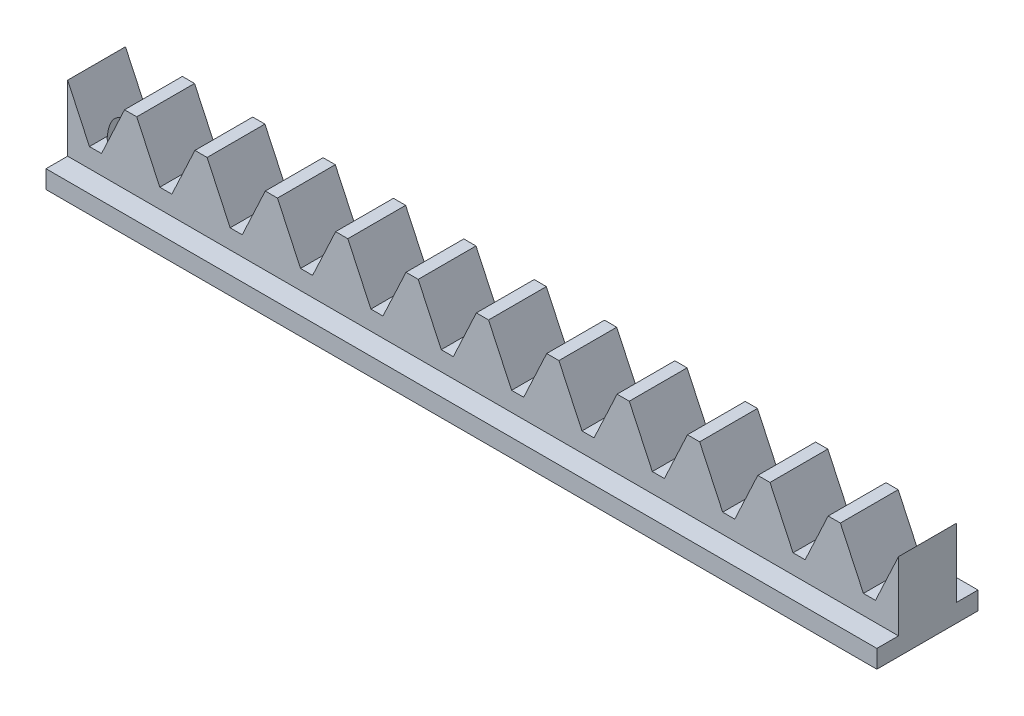
from build123d import *

# Parameters (mm, degrees)
BOSS_EXTRUDE4_DEPTH = 4
CUT_EXTRUDE7_DEPTH  = 5
LPATTERN2_COUNT     = 13
LPATTERN2_PITCH     = 9.7389
SKETCH10_W          = 14
SKETCH10_H          = 2.5
BOSS_EXTRUDE5_DEPTH = 115
SKETCH11_R          = 2.5
CUT_EXTRUDE8_DEPTH  = 13


with BuildPart() as part:
    # Sketch9 → Boss-Extrude4 (new body, symmetric)
    with BuildSketch(Plane.XY):
        Polygon((57.5, 6), (49.449989311, 6), (52.64, -0.841), (54.309989311, -0.841), align=None)
        Polygon((52.64, -0.841), (49.449989311, 6), (-57.5, 6), (-57.5, -6), (57.5, -6), (57.5, 6), (54.309989311, -0.841), align=None)
    extrude(amount=BOSS_EXTRUDE4_DEPTH, both=True)

    # Sketch9_4 → Cut-Extrude7 (cut, symmetric)
    with BuildSketch(Plane.XY):
        Polygon((57.5, 6), (49.449989311, 6), (52.64, -0.841), (54.309989311, -0.841), align=None)
    cut_extrude7 = extrude(amount=CUT_EXTRUDE7_DEPTH, both=True, mode=Mode.SUBTRACT)

    # LPattern2: Cut-Extrude7 ×13
    with Locations(*[(-i * LPATTERN2_PITCH, 0, 0) for i in range(1, LPATTERN2_COUNT)]):
        add(cut_extrude7, mode=Mode.SUBTRACT)

    # Sketch10 → Boss-Extrude5 (add)
    with BuildSketch(Plane.ZY.offset(57.5)):
        with Locations((0, -4.75)):
            Rectangle(SKETCH10_W, SKETCH10_H)
    extrude(amount=-BOSS_EXTRUDE5_DEPTH)

    # Sketch11 → Cut-Extrude8 (cut, through all)
    with BuildSketch(Plane.XZ.offset(6)):
        with Locations((-52.5, 0)):
            Circle(SKETCH11_R)
    extrude(amount=-CUT_EXTRUDE8_DEPTH, mode=Mode.SUBTRACT)


solid = part.part
